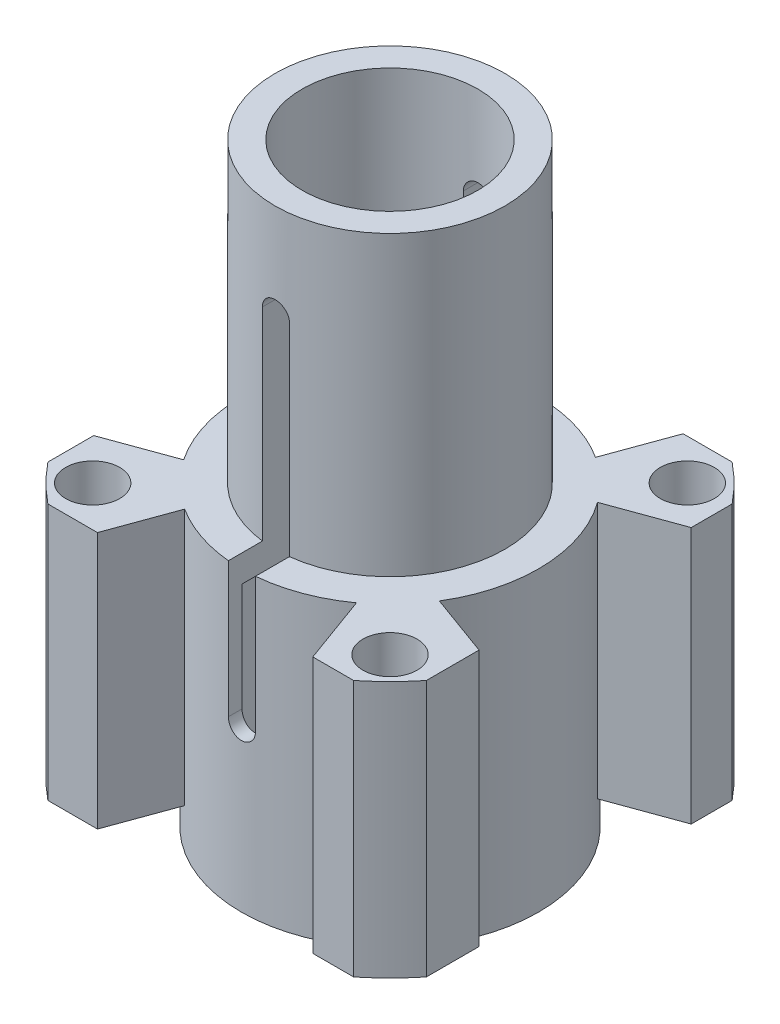
from build123d import *

# Parameters (mm, degrees)
ESQUISSE3_R      = 2
ESQUISSE3_R_2    = 10
EXTRUSION2_DEPTH = 19
EXTRUSION4_DEPTH = 29


with BuildPart() as part:
    # Esquisse1 → Révolution1 (revolve)
    with BuildSketch(Plane.XY):
        Polygon((-6.5, 20), (-6.5, 44), (-8.5, 44), (-8.5, 22), (-11, 22), (-11, 0), (-10, 0), (-10, 20), align=None)
    revolve(axis=Axis((0, 0, 0), (0, 1, 0)))

    # Esquisse3 → Extrusion2 (add)
    with BuildSketch(Plane(origin=(0, 22, 0), x_dir=(1, 0, 0), z_dir=(0, 1, 0))):
        with BuildLine():
            Line((-11.313708499, -14), (-7.645328987, -14))
            Line((-7.645328987, -14), (-5.923372103, -9.268962344))
            ThreePointArc((-5.923372103, -9.268962344), (0.311535181, -10.995587562), (6.438678833, -8.918711504))
            Line((6.438678833, -8.918711504), (8.288116597, -14))
            Line((8.288116597, -14), (11.313708499, -14))
            ThreePointArc((11.313708499, -14), (12.727922061, -12.727922061), (14, -11.313708499))
            Line((14, -11.313708499), (14, -7.411373431))
            Line((14, -7.411373431), (9.388048674, -5.732760426))
            ThreePointArc((9.388048674, -5.732760426), (10.991831078, 0.423850851), (8.918711504, 6.438678833))
            Line((8.918711504, 6.438678833), (14, 8.288116597))
            Line((14, 8.288116597), (14, 11.313708499))
            ThreePointArc((14, 11.313708499), (12.727922061, 12.727922061), (11.313708499, 14))
            Line((11.313708499, 14), (7.690190806, 14))
            Line((7.690190806, 14), (5.959738542, 9.245621478))
            ThreePointArc((5.959738542, 9.245621478), (-0.112996861, 10.999419608), (-6.148420959, 9.12123455))
            Line((-6.148420959, 9.12123455), (-7.924146363, 14))
            Line((-7.924146363, 14), (-11.313708499, 14))
            ThreePointArc((-11.313708499, 14), (-12.727922061, 12.727922061), (-14, 11.313708499))
            Line((-14, 11.313708499), (-14, 7.924146363))
            Line((-14, 7.924146363), (-9.12123455, 6.148420959))
            ThreePointArc((-9.12123455, 6.148420959), (-11, 0), (-9.12123455, -6.148420959))
            Line((-9.12123455, -6.148420959), (-14, -7.924146363))
            Line((-14, -7.924146363), (-14, -11.313708499))
            ThreePointArc((-14, -11.313708499), (-12.727922061, -12.727922061), (-11.313708499, -14))
        make_face()
        with Locations((11, 11)):
            Circle(ESQUISSE3_R, mode=Mode.SUBTRACT)
        with Locations((-11, -11)):
            Circle(ESQUISSE3_R, mode=Mode.SUBTRACT)
        with Locations((-11, 11)):
            Circle(ESQUISSE3_R, mode=Mode.SUBTRACT)
        with Locations((11, -11)):
            Circle(ESQUISSE3_R, mode=Mode.SUBTRACT)
        Circle(ESQUISSE3_R_2, mode=Mode.SUBTRACT)
    extrude(amount=-EXTRUSION2_DEPTH)

    # Esquisse4 → Extrusion4 (cut, through all)
    with BuildSketch(Plane.XY.offset(14)):
        with BuildLine():
            Line((-1, 37), (-1, 12))
            ThreePointArc((-1, 12), (0, 11), (1, 12))
            Line((1, 12), (1, 37))
            ThreePointArc((1, 37), (0, 38), (-1, 37))
        make_face()
    extrude(amount=-EXTRUSION4_DEPTH, mode=Mode.SUBTRACT)


solid = part.part
